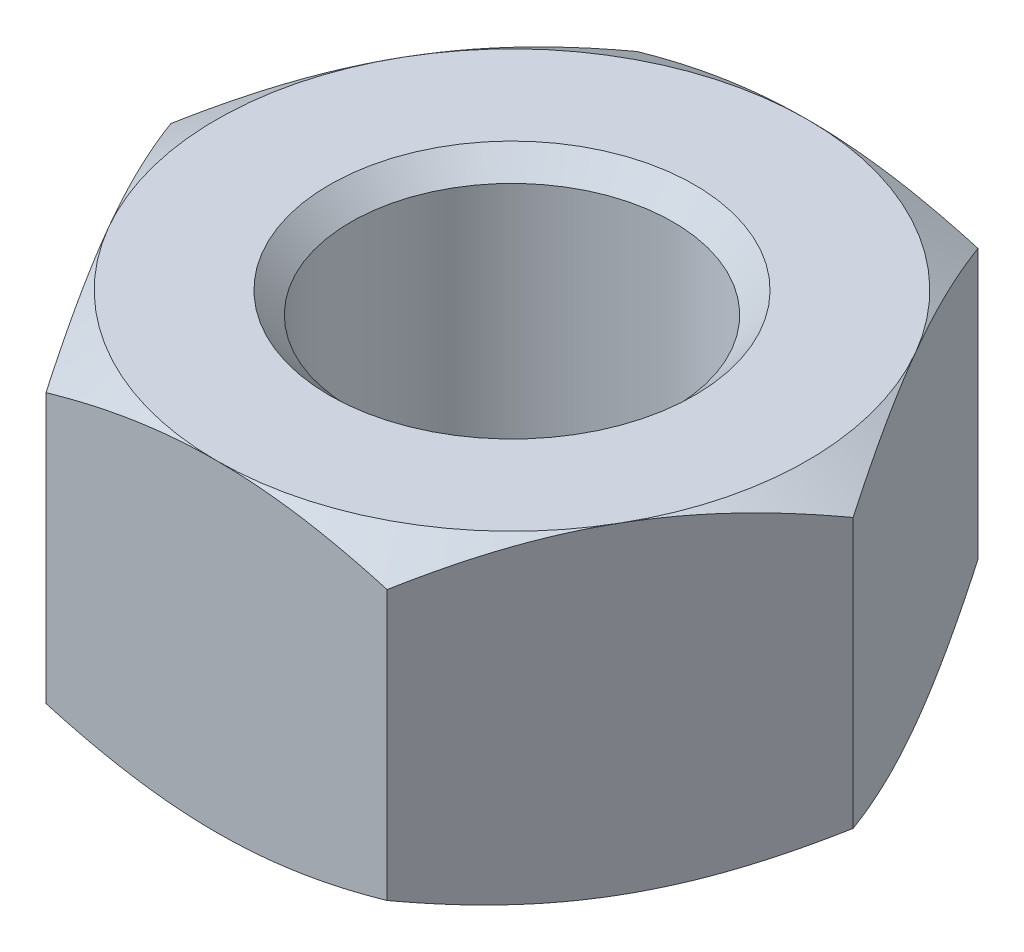
from build123d import *

# Parameters (mm, degrees)
SKETCH1_R           = 4.7625
BOSS_EXTRUDE1_DEPTH = 9.525
SKETCH2_OUTSIDE_W   = 60.842
SKETCH2_OUTSIDE_H   = 58.14
SKETCH2_OUTSIDE_R   = 8.7376
CUT_EXTRUDE1_DEPTH  = 9.525
CUT_EXTRUDE1_TAPER  = 60
SKETCH3_OUTSIDE_W   = 60.842
SKETCH3_OUTSIDE_H   = 58.14
SKETCH3_OUTSIDE_R   = 8.7376
CUT_EXTRUDE2_DEPTH  = 9.525
CUT_EXTRUDE2_TAPER  = 60
CHAMFER1_SIZE       = 0.635


with BuildPart() as part:
    # Sketch1 → Boss-Extrude1 (new body)
    with BuildSketch(Plane(origin=(0, 0, 0), x_dir=(1, 0, 0), z_dir=(0, 1, 0))):
        Polygon((10.089311424, 0), (5.044655712, 8.7376), (-5.044655712, 8.7376), (-10.089311424, 0), (-5.044655712, -8.7376), (5.044655712, -8.7376), align=None)
        Circle(SKETCH1_R, mode=Mode.SUBTRACT)
    extrude(amount=BOSS_EXTRUDE1_DEPTH)

    # Sketch2 outside → Cut-Extrude1 (cut)
    with BuildSketch(Plane(origin=(0, 9.525, 0), x_dir=(1, 0, 0), z_dir=(0, 1, 0))):
        Rectangle(SKETCH2_OUTSIDE_W, SKETCH2_OUTSIDE_H)
        Circle(SKETCH2_OUTSIDE_R, mode=Mode.SUBTRACT)
    extrude(amount=-CUT_EXTRUDE1_DEPTH, taper=CUT_EXTRUDE1_TAPER, mode=Mode.SUBTRACT)

    # Sketch3 outside → Cut-Extrude2 (cut)
    with BuildSketch(Plane.XZ):
        Rectangle(SKETCH3_OUTSIDE_W, SKETCH3_OUTSIDE_H)
        Circle(SKETCH3_OUTSIDE_R, mode=Mode.SUBTRACT)
    extrude(amount=-CUT_EXTRUDE2_DEPTH, taper=CUT_EXTRUDE2_TAPER, mode=Mode.SUBTRACT)

    # Chamfer1
    chamfer1_edges = [part.edges().sort_by_distance(p)[0] for p in [
        (-4.7625, 0, 0),
        (-4.7625, 9.525, 0),
    ]]
    chamfer(chamfer1_edges, length=CHAMFER1_SIZE)


solid = part.part
